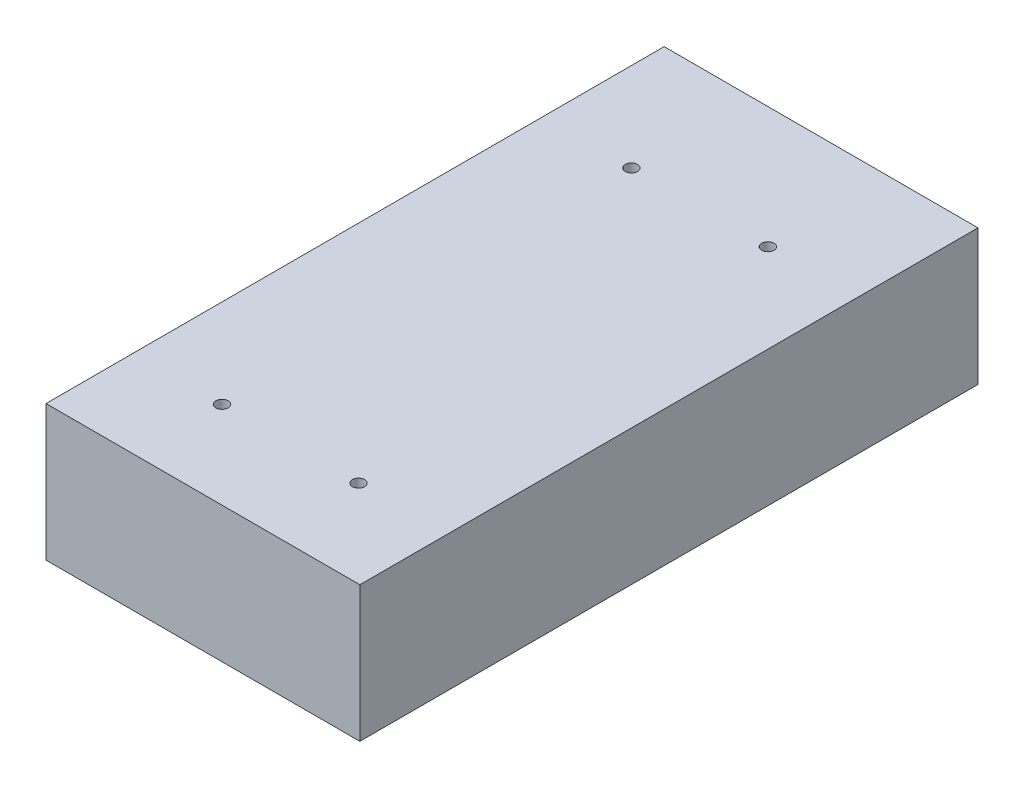
from build123d import *

# Parameters (mm, degrees)
SKETCH3_W                                       = 115
SKETCH3_H                                       = 226.5
BOSS_EXTRUDE1_DEPTH                             = 49.7
CSK_FOR_M4_FLAT_HEAD_MACHINE_SCREW2_D           = 4.5
CSK_FOR_M4_FLAT_HEAD_MACHINE_SCREW2_CSINK_D     = 9.4
CSK_FOR_M4_FLAT_HEAD_MACHINE_SCREW2_CSINK_ANGLE = 90
SKETCH8_W                                       = 112.444388117
SKETCH8_H                                       = 18.583241451
CUT_EXTRUDE1_DEPTH                              = 48
CUT_EXTRUDE2_DEPTH                              = 6
M4_CLEARANCE_HOLE1_D                            = 4.5
M4_CLEARANCE_HOLE1_DEPTH                        = 5
M4_CLEARANCE_HOLE1_TIP                          = 1.351936393


with BuildPart() as part:
    # Sketch3 → Boss-Extrude1 (new body)
    with BuildSketch(Plane(origin=(0, 0, 0), x_dir=(1, 0, 0), z_dir=(0, 1, 0))):
        with Locations((57.5, 113.25)):
            Rectangle(SKETCH3_W, SKETCH3_H)
    extrude(amount=BOSS_EXTRUDE1_DEPTH)

    # CSK for M4 Flat Head Machine Screw2 (through all)
    with Locations(Plane(origin=(0, 0, 0), x_dir=(-1, 0, 0), z_dir=(0, -1, 0))):
        with Locations((-32.5, 32), (-82.5, 32), (-82.5, 182), (-32.5, 182)):
            CounterSinkHole(CSK_FOR_M4_FLAT_HEAD_MACHINE_SCREW2_D / 2, CSK_FOR_M4_FLAT_HEAD_MACHINE_SCREW2_CSINK_D / 2, counter_sink_angle=CSK_FOR_M4_FLAT_HEAD_MACHINE_SCREW2_CSINK_ANGLE)

    # Sketch8 → Cut-Extrude1 (cut)
    with BuildSketch(Plane(origin=(0, 0, 0), x_dir=(-1, 0, 0), z_dir=(0, -1, 0))):
        with Locations((-57.518541752, 217.208379275)):
            Rectangle(SKETCH8_W, SKETCH8_H)
    extrude(amount=-CUT_EXTRUDE1_DEPTH, mode=Mode.SUBTRACT)

    # Sketch9 → Cut-Extrude2 (cut)
    with BuildSketch(Plane(origin=(0, 0, 0), x_dir=(-1, 0, 0), z_dir=(0, -1, 0))):
        with BuildLine():
            ThreePointArc((-35.24160151, 50.698787363), (-29.906155704, 57.837710564), (-28.013949561, 66.546944878))
            ThreePointArc((-28.013949561, 66.546944878), (-29.740661802, 68.27365712), (-31.467374044, 66.546944878))
            ThreePointArc((-31.467374044, 66.546944878), (-33.0482468, 59.270680978), (-37.505827146, 53.306357674))
            ThreePointArc((-37.505827146, 53.306357674), (-37.677499484, 50.870459701), (-35.24160151, 50.698787363))
        make_face()
        with BuildLine():
            ThreePointArc((-62.815145497, 50.64033664), (-56.375233323, 46.812564416), (-49.002996311, 45.480486923))
            ThreePointArc((-49.002996311, 45.480486923), (-47.198872865, 47.284610369), (-49.002996311, 49.088733815))
            ThreePointArc((-49.002996311, 49.088733815), (-55.112522176, 50.192654089), (-60.449411092, 53.364808398))
            ThreePointArc((-60.449411092, 53.364808398), (-62.994514173, 53.185439721), (-62.815145497, 50.64033664))
        make_face()
        with BuildLine():
            ThreePointArc((-68.572182043, 75.27774008), (-69.961499926, 71.01023305), (-70.43147771, 66.546944878))
            ThreePointArc((-70.43147771, 66.546944878), (-68.26533082, 64.380797988), (-66.09918393, 66.546944878))
            ThreePointArc((-66.09918393, 66.546944878), (-65.724223696, 70.107869732), (-64.615790544, 73.512595409))
            ThreePointArc((-64.615790544, 73.512595409), (-65.711413958, 76.373363494), (-68.572182043, 75.27774008))
        make_face()
        with BuildLine():
            ThreePointArc((-35.258623929, 82.375498714), (-41.66693518, 86.184487896), (-49.002996311, 87.510028828))
            ThreePointArc((-49.002996311, 87.510028828), (-50.703745752, 85.809279387), (-49.002996311, 84.108529946))
            ThreePointArc((-49.002996311, 84.108529946), (-42.857294566, 82.998073111), (-37.488804727, 79.807135761))
            ThreePointArc((-37.488804727, 79.807135761), (-35.089532852, 79.976226838), (-35.258623929, 82.375498714))
        make_face()
        with BuildLine():
            ThreePointArc((-69.40308911, 47.094937136), (-60.098890521, 40.635064917), (-49.002996311, 38.359281062))
            ThreePointArc((-49.002996311, 38.359281062), (-47.430907963, 39.93136941), (-49.002996311, 41.503457758))
            ThreePointArc((-49.002996311, 41.503457758), (-58.861205404, 43.525390616), (-67.12757253, 49.264700116))
            ThreePointArc((-67.12757253, 49.264700116), (-69.35021231, 49.317576916), (-69.40308911, 47.094937136))
        make_face()
        with BuildLine():
            ThreePointArc((-76.955702254, 72.084205228), (-77.381483247, 63.963052285), (-75.495983574, 56.052344001))
            ThreePointArc((-75.495983574, 56.052344001), (-73.055355825, 54.99668972), (-71.999701544, 57.437317469))
            ThreePointArc((-71.999701544, 57.437317469), (-73.636371647, 64.304048834), (-73.266781011, 71.353452457))
            ThreePointArc((-73.266781011, 71.353452457), (-74.745865247, 73.563289464), (-76.955702254, 72.084205228))
        make_face()
        with BuildLine():
            ThreePointArc((-61.479475854, 92.737765271), (-67.474162168, 88.917408587), (-72.359830302, 83.7539179))
            ThreePointArc((-72.359830302, 83.7539179), (-71.852094521, 80.404948498), (-68.503125119, 80.912684278))
            ThreePointArc((-68.503125119, 80.912684278), (-64.424183685, 85.223573911), (-59.419346329, 88.41310925))
            ThreePointArc((-59.419346329, 88.41310925), (-58.287083081, 91.605502023), (-61.479475854, 92.737765271))
        make_face()
        with BuildLine():
            ThreePointArc((-30.044644277, 88.193682414), (-37.532685074, 92.936949007), (-46.109148954, 95.176056029))
            ThreePointArc((-46.109148954, 95.176056029), (-48.474789772, 93.244752833), (-46.543486577, 90.879112015))
            ThreePointArc((-46.543486577, 90.879112015), (-39.254264376, 88.976072623), (-32.890103811, 84.944723032))
            ThreePointArc((-32.890103811, 84.944723032), (-29.842894353, 85.146472956), (-30.044644277, 88.193682414))
        make_face()
        with BuildLine():
            ThreePointArc((-22.242703071, 56.799039322), (-20.547999949, 65.343558372), (-21.515231892, 74.000652968))
            ThreePointArc((-21.515231892, 74.000652968), (-23.803146789, 75.312452747), (-25.114946569, 73.02453785))
            ThreePointArc((-25.114946569, 73.02453785), (-24.274380402, 65.501150237), (-25.747150317, 58.075595617))
            ThreePointArc((-25.747150317, 58.075595617), (-24.633204841, 55.685093846), (-22.242703071, 56.799039322))
        make_face()
        with BuildLine():
            ThreePointArc((-39.301431481, 39.586636452), (-33.365347236, 42.53772744), (-28.266328256, 46.774004062))
            ThreePointArc((-28.266328256, 46.774004062), (-28.334847238, 49.654152172), (-31.214995349, 49.58563319))
            ThreePointArc((-31.214995349, 49.58563319), (-35.588955249, 45.951737309), (-40.680953248, 43.420279064))
            ThreePointArc((-40.680953248, 43.420279064), (-41.90801367, 40.813696874), (-39.301431481, 39.586636452))
        make_face()
    extrude(amount=-CUT_EXTRUDE2_DEPTH, mode=Mode.SUBTRACT)

    # M4 Clearance Hole1
    with Locations(Plane.ZY):
        with Locations((-32.5, 37), (-182.5, 37)):
            Hole(M4_CLEARANCE_HOLE1_D / 2, depth=M4_CLEARANCE_HOLE1_DEPTH)
            with Locations((0, 0, -(M4_CLEARANCE_HOLE1_DEPTH + M4_CLEARANCE_HOLE1_TIP / 2))):  # 118° drill point
                Cone(0, M4_CLEARANCE_HOLE1_D / 2, M4_CLEARANCE_HOLE1_TIP, mode=Mode.SUBTRACT)


solid = part.part
